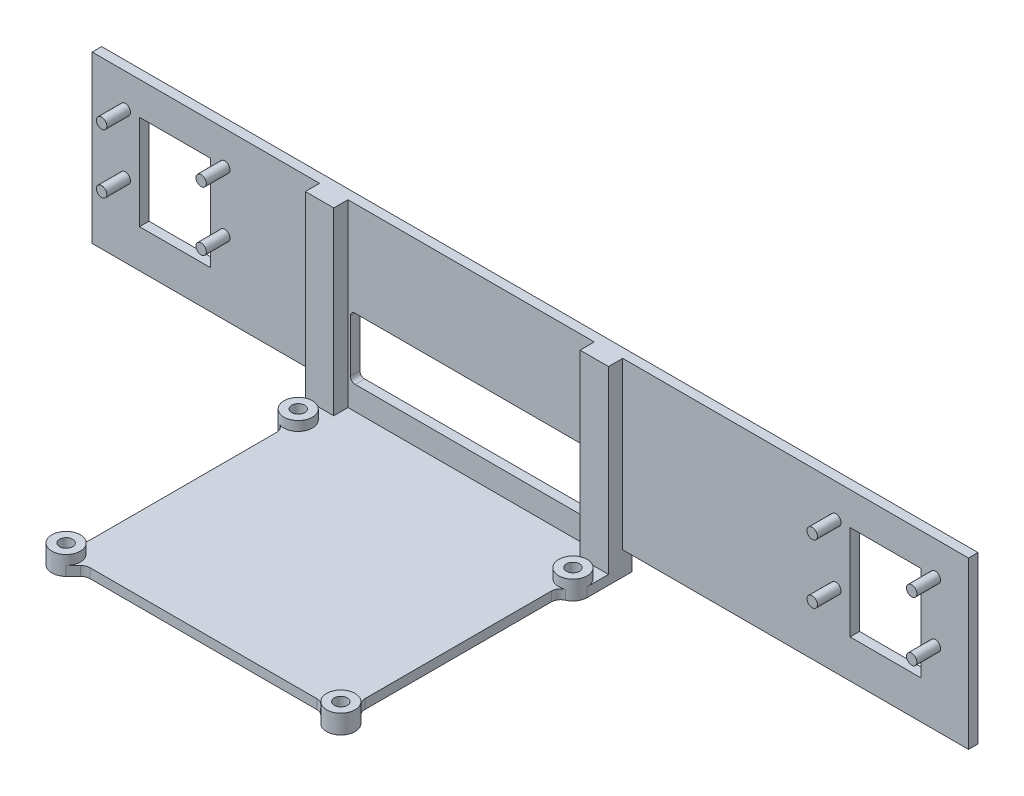
from build123d import *

# Parameters (mm, degrees)
BOSS_EXTRUDE1_DEPTH = 2
SKETCH8_R           = 1.1
BOSS_EXTRUDE4_DEPTH = 5
SKETCH2_W           = 75
SKETCH2_H           = 2
BOSS_EXTRUDE2_DEPTH = 65
SKETCH9_W           = 15
SKETCH9_H           = 20
CUT_EXTRUDE2_DEPTH  = 120.921849552
SKETCH10_R          = 1.375
CUT_EXTRUDE3_DEPTH  = 122.017560709
SKETCH11_R          = 3
SKETCH11_R_2        = 1.375
BOSS_EXTRUDE5_DEPTH = 2
CUT_EXTRUDE4_DEPTH  = 121.371300566
SKETCH16_W          = 5.5
SKETCH16_H          = 5
CUT_EXTRUDE5_DEPTH  = 118.032046893
SKETCH17_W          = 6
SKETCH17_H          = 38
BOSS_EXTRUDE6_DEPTH = 3
SKETCH18_W          = 51
SKETCH18_H          = 13
CUT_EXTRUDE6_DEPTH  = 118.032046893
FILLET1_R           = 1


with BuildPart() as part:
    # Sketch1 → Boss-Extrude1 (new body)
    with BuildSketch(Plane.XY):
        Polygon((-50, 5), (-50, 0), (25, 0), (25, 5), (92.5, 5), (92.5, 40), (57.5, 40), (-57.5, 40), (-92.5, 40), (-92.5, 5), align=None)
    extrude(amount=BOSS_EXTRUDE1_DEPTH)

    # Sketch8 → Boss-Extrude4 (add)
    with BuildSketch(Plane.XY.offset(2)):
        with Locations((-85.5, 33)):
            Circle(SKETCH8_R)
        with Locations((-64.5, 33)):
            Circle(SKETCH8_R)
        with Locations((-85.5, 20.5)):
            Circle(SKETCH8_R)
        with Locations((-64.5, 20.5)):
            Circle(SKETCH8_R)
    boss_extrude4 = extrude(amount=BOSS_EXTRUDE4_DEPTH)

    # Mirror2: Boss-Extrude4 across plane
    add(boss_extrude4.mirror(Plane(origin=(0, 0, 0), x_dir=(0, 0, 1), z_dir=(1, 0, 0))))

    # Sketch2 → Boss-Extrude2 (add)
    with BuildSketch(Plane.XY.offset(2)):
        with Locations((-12.5, 1)):
            Rectangle(SKETCH2_W, SKETCH2_H)
    extrude(amount=BOSS_EXTRUDE2_DEPTH)

    # Sketch9 → Cut-Extrude2 (cut, through all)
    with BuildSketch(Plane.XY.offset(2)):
        with Locations((-75, 23.069)):
            Rectangle(SKETCH9_W, SKETCH9_H)
        with Locations((75, 23.069)):
            Rectangle(SKETCH9_W, SKETCH9_H)
    extrude(amount=-CUT_EXTRUDE2_DEPTH, mode=Mode.SUBTRACT)

    # Sketch10 → Cut-Extrude3 (cut, through all)
    with BuildSketch(Plane.XZ):
        with Locations(Location((-41.5, 58.5, 0), (0, 0, 270))):
            Circle(SKETCH10_R)
        with Locations(Location((-41.5, 9.5, 0), (0, 0, 270))):
            Circle(SKETCH10_R)
        with Locations(Location((16.5, 9.5, 0), (0, 0, 270))):
            Circle(SKETCH10_R)
        with Locations(Location((16.5, 58.5, 0), (0, 0, 270))):
            Circle(SKETCH10_R)
    extrude(amount=-CUT_EXTRUDE3_DEPTH, mode=Mode.SUBTRACT)

    # Sketch11 → Boss-Extrude5 (add)
    with BuildSketch(Plane(origin=(0, 2, 0), x_dir=(1, 0, 0), z_dir=(0, 1, 0))):
        with Locations((-41.5, -9.5)):
            Circle(SKETCH11_R)
        with Locations(Location((-41.5, -9.5, 0), (0, 0, 90))):
            Circle(SKETCH11_R_2, mode=Mode.SUBTRACT)
    boss_extrude5 = extrude(amount=BOSS_EXTRUDE5_DEPTH)

    # Sketch-Pattern1: Boss-Extrude5 at 3 more places
    with Locations((58, 0, 0), (58, 0, 49), (0, 0, 49)):
        add(boss_extrude5)

    # Sketch15 → Cut-Extrude4 (cut, through all)
    with BuildSketch(Plane(origin=(0, 2, 0), x_dir=(1, 0, 0), z_dir=(0, 1, 0))):
        with BuildLine():
            ThreePointArc((-42.7, -12.249545417), (-44.00998008, -11.143167673), (-44.5, -9.5))
            Line((-44.5, -9.5), (-44.5, -2))
            Line((-44.5, -2), (-50, -2))
            Line((-50, -2), (-50, -67))
            Line((-50, -67), (25, -67))
            Line((25, -67), (25, -2))
            Line((25, -2), (19.5, -2))
            Line((19.5, -2), (19.5, -9.5))
            ThreePointArc((19.5, -9.5), (19.00998008, -11.143167673), (17.7, -12.249545417))
            ThreePointArc((17.7, -12.249545417), (16.826679947, -12.98713058), (16.5, -14.082575695))
            Line((16.5, -14.082575695), (16.5, -53.428932188))
            ThreePointArc((16.5, -53.428932188), (16.652240935, -54.194299053), (17.085786438, -54.843145751))
            Line((17.085786438, -54.843145751), (18.621320344, -56.378679656))
            ThreePointArc((18.621320344, -56.378679656), (19.271638598, -57.351949703), (19.5, -58.5))
            ThreePointArc((19.5, -58.5), (17.648050297, -61.271638598), (14.378679656, -60.621320344))
            Line((14.378679656, -60.621320344), (12.843145751, -59.085786438))
            ThreePointArc((12.843145751, -59.085786438), (12.194299053, -58.652240935), (11.428932188, -58.5))
            Line((11.428932188, -58.5), (-36.428932188, -58.5))
            ThreePointArc((-36.428932188, -58.5), (-37.194299053, -58.652240935), (-37.843145751, -59.085786438))
            Line((-37.843145751, -59.085786438), (-39.378679656, -60.621320344))
            ThreePointArc((-39.378679656, -60.621320344), (-43.621320344, -60.621320344), (-43.621320344, -56.378679656))
            Line((-43.621320344, -56.378679656), (-42.085786438, -54.843145751))
            ThreePointArc((-42.085786438, -54.843145751), (-41.652240935, -54.194299053), (-41.5, -53.428932188))
            Line((-41.5, -53.428932188), (-41.5, -14.082575695))
            ThreePointArc((-41.5, -14.082575695), (-41.826679947, -12.98713058), (-42.7, -12.249545417))
        make_face()
    extrude(amount=-CUT_EXTRUDE4_DEPTH, mode=Mode.SUBTRACT)

    # Sketch16 → Cut-Extrude5 (cut, through all)
    with BuildSketch(Plane.XY.offset(2)):
        with Locations((-47.25, 2.5)):
            Rectangle(SKETCH16_W, SKETCH16_H)
        with Locations((22.25, 2.5)):
            Rectangle(SKETCH16_W, SKETCH16_H)
    extrude(amount=-CUT_EXTRUDE5_DEPTH, mode=Mode.SUBTRACT)

    # Sketch17 → Boss-Extrude6 (add)
    with BuildSketch(Plane.XY.offset(2)):
        with Locations((-41.5, 21)):
            Rectangle(SKETCH17_W, SKETCH17_H)
        with Locations((16.5, 21)):
            Rectangle(SKETCH17_W, SKETCH17_H)
    extrude(amount=BOSS_EXTRUDE6_DEPTH)

    # Sketch18 → Cut-Extrude6 (cut, through all)
    with BuildSketch(Plane.XY.offset(2)):
        with Locations((-12.5, 13.5)):
            Rectangle(SKETCH18_W, SKETCH18_H)
    extrude(amount=-CUT_EXTRUDE6_DEPTH, mode=Mode.SUBTRACT)

    # Fillet1
    fillet1_edges = [part.edges().sort_by_distance(p)[0] for p in [
        (-38, 20, 1),
        (13, 20, 1),
        (13, 7, 1),
        (-38, 7, 1),
    ]]
    fillet(fillet1_edges, radius=FILLET1_R)


solid = part.part
